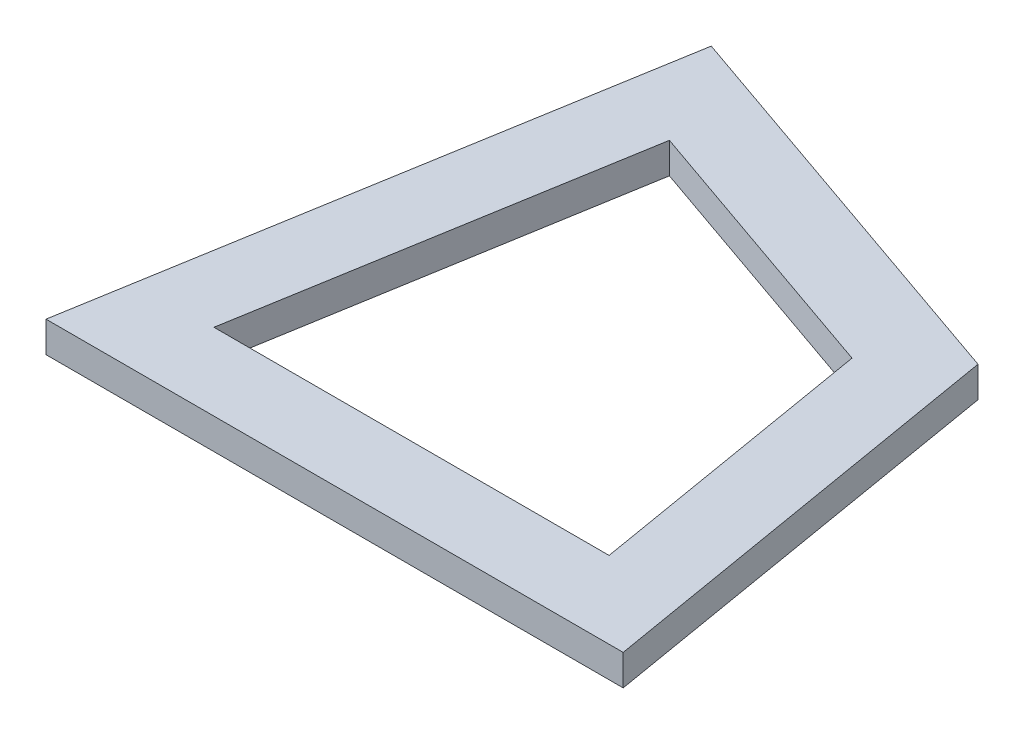
from build123d import *

# Parameters (mm, degrees)
BOSS_EXTRUDE1_DEPTH = 2


with BuildPart() as part:
    # Sketch1 → Boss-Extrude1 (new body)
    with BuildSketch(Plane(origin=(0, 0, 0), x_dir=(1, 0, 0), z_dir=(0, 1, 0))):
        Polygon((0, 0), (37.51212321, 0), (32.823562265, 27.749890282), (6.249394264, 36.987896116), align=None)
        Polygon((10.19418297, 30.323061182), (5.915653777, 5), (31.596469433, 5), (28.386463539, 23.998859649), align=None, mode=Mode.SUBTRACT)
    extrude(amount=BOSS_EXTRUDE1_DEPTH)


solid = part.part
